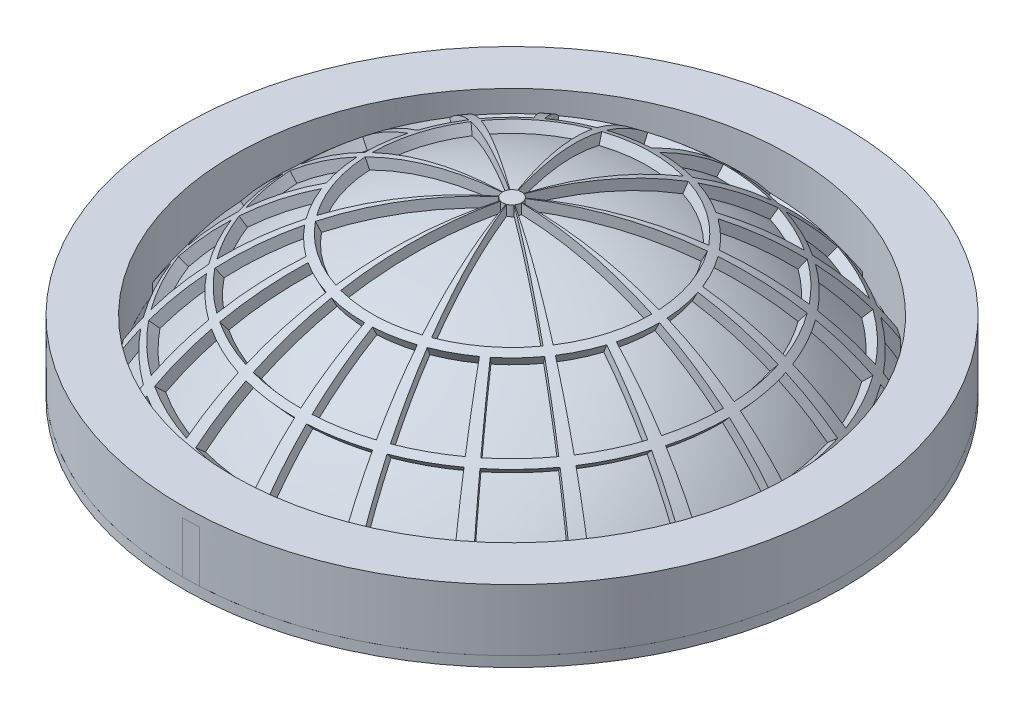
from build123d import *

# Parameters (mm, degrees)
REVOLVE_2_ANGLE          = 3
REVOLVE_3_ANGLE          = 3
PATTERN_CIRCULAR_3_COUNT = 20
PATTERN_CIRCULAR_4_COUNT = 10
EXTRUDE_START            = -60
SKETCH_2_R               = 321.293199325
SKETCH_2_R_2             = 271.293199325
EXTRUDE_1_DEPTH          = 10
SKETCH_2_2_R             = 321.293199325
SKETCH_2_2_R_2           = 271.293199325
EXTRUDE_2_DEPTH          = 10
EXTRUDE_3_DEPTH          = 60
EXTRUDE_4_DEPTH          = 50


with BuildPart() as part:
    # Sketch 1 → Revolve 1 (revolve)
    with BuildSketch(Plane.XY):
        with BuildLine():
            Line((0, 310), (0, 300))
            ThreePointArc((0, 300), (150, 259.807621135), (259.807621135, 150))
            Line((259.807621135, 150), (271.293199325, 150))
            ThreePointArc((271.293199325, 150), (260.86202693, 167.484336301), (249.30566955, 184.246256761))
            ThreePointArc((249.30566955, 184.246256761), (246.702616609, 187.717391199), (244.051238042, 191.151754399))
            ThreePointArc((244.051238042, 191.151754399), (225.561573766, 212.654594214), (205.184234191, 232.377774409))
            ThreePointArc((205.184234191, 232.377774409), (202.413399752, 234.795263157), (199.614084683, 237.179714976))
            ThreePointArc((199.614084683, 237.179714976), (170.612647572, 258.826823356), (139.286048295, 276.946559376))
            ThreePointArc((139.286048295, 276.946559376), (135.698993593, 278.721694774), (132.089320414, 280.450372495))
            ThreePointArc((132.089320414, 280.450372495), (72.146553697, 301.487768889), (9.174001596, 309.864224613))
            ThreePointArc((9.174001596, 309.864224613), (4.58750314, 309.966054295), (0, 310))
        make_face()
        with BuildLine():
            Line((136.350266234, 289.497158705), (132.089320414, 280.450372495))
            ThreePointArc((132.089320414, 280.450372495), (135.698993593, 278.721694774), (139.286048295, 276.946559376))
            Line((139.286048295, 276.946559376), (143.779146627, 285.880319356))
            ThreePointArc((143.779146627, 285.880319356), (140.076380483, 287.712717186), (136.350266234, 289.497158705))
        make_face()
        with BuildLine():
            Line((206.053248705, 244.830673524), (199.614084683, 237.179714976))
            ThreePointArc((199.614084683, 237.179714976), (202.413399752, 234.795263157), (205.184234191, 232.377774409))
            Line((205.184234191, 232.377774409), (211.803080455, 239.873831648))
            ThreePointArc((211.803080455, 239.873831648), (208.94286426, 242.369303904), (206.053248705, 244.830673524))
        make_face()
        with BuildLine():
            ThreePointArc((244.051238042, 191.151754399), (246.702616609, 187.717391199), (249.30566955, 184.246256761))
            Line((249.30566955, 184.246256761), (257.347787922, 190.189684398))
            ThreePointArc((257.347787922, 190.189684398), (254.660765532, 193.772790915), (251.923858624, 197.317940025))
            Line((251.923858624, 197.317940025), (244.051238042, 191.151754399))
        make_face()
        with BuildLine():
            Line((0, 320), (0, 310))
            ThreePointArc((0, 310), (4.58750314, 309.966054295), (9.174001596, 309.864224613))
            Line((9.174001596, 309.864224613), (9.174001596, 319.868469366))
            ThreePointArc((9.174001596, 319.868469366), (4.587472223, 319.967115652), (0, 320))
        make_face()
    revolve(axis=Axis((0, 300, 0), (0, -1, 0)))

    # Sketch 1_3 → Revolve 2 (revolve)
    with BuildSketch(Plane.XY):
        with BuildLine():
            Line((9.174001596, 319.868469366), (9.174001596, 309.864224613))
            ThreePointArc((9.174001596, 309.864224613), (72.146553697, 301.487768889), (132.089320414, 280.450372495))
            Line((132.089320414, 280.450372495), (136.350266234, 289.497158705))
            ThreePointArc((136.350266234, 289.497158705), (74.329888064, 311.24759877), (9.174001596, 319.868469366))
        make_face()
    revolve_2 = revolve(axis=Axis((0, 300, 0), (0, 1, 0)), revolution_arc=REVOLVE_2_ANGLE)

    # Sketch 1_5 → Revolve 3 (revolve)
    with BuildSketch(Plane.XY):
        with BuildLine():
            ThreePointArc((249.30566955, 184.246256761), (260.86202693, 167.484336301), (271.293199325, 150))
            Line((271.293199325, 150), (282.665880502, 150))
            ThreePointArc((282.665880502, 150), (270.753565451, 170.565256708), (257.347787922, 190.189684398))
            Line((257.347787922, 190.189684398), (249.30566955, 184.246256761))
        make_face()
        with BuildLine():
            Line((143.779146627, 285.880319356), (139.286048295, 276.946559376))
            ThreePointArc((139.286048295, 276.946559376), (170.612647572, 258.826823356), (199.614084683, 237.179714976))
            Line((199.614084683, 237.179714976), (206.053248705, 244.830673524))
            ThreePointArc((206.053248705, 244.830673524), (176.116281365, 267.176075722), (143.779146627, 285.880319356))
        make_face()
        with BuildLine():
            ThreePointArc((205.184234191, 232.377774409), (225.561573766, 212.654594214), (244.051238042, 191.151754399))
            Line((244.051238042, 191.151754399), (251.923858624, 197.317940025))
            ThreePointArc((251.923858624, 197.317940025), (232.837753565, 219.514419834), (211.803080455, 239.873831648))
            Line((211.803080455, 239.873831648), (205.184234191, 232.377774409))
        make_face()
    revolve_3 = revolve(axis=Axis((0, 300, 0), (0, 1, 0)), revolution_arc=REVOLVE_3_ANGLE)

    # Pattern Circular 3: Revolve 3 ×20 about axis
    pattern_circular_3_axis = Axis((0, 0, 0), (0, 1, 0))
    for i in range(1, PATTERN_CIRCULAR_3_COUNT):
        add(revolve_3.rotate(pattern_circular_3_axis, i * 360 / PATTERN_CIRCULAR_3_COUNT))

    # Pattern Circular 4: Revolve 2 ×10 about axis
    pattern_circular_4_axis = Axis((0, 0, 0), (0, 1, 0))
    for i in range(1, PATTERN_CIRCULAR_4_COUNT):
        add(revolve_2.rotate(pattern_circular_4_axis, i * 360 / PATTERN_CIRCULAR_4_COUNT))


with BuildPart() as body_2:
    # Sketch 2 → Extrude 1 (new body)
    with BuildSketch(Plane(origin=(0, 150, 0), x_dir=(-1, 0, 0), z_dir=(0, -1, 0)).offset(EXTRUDE_START)):
        Circle(SKETCH_2_R)
        Circle(SKETCH_2_R_2, mode=Mode.SUBTRACT)
    extrude(amount=-EXTRUDE_1_DEPTH)


    add(part.part)  # Extrude 3 merges part
    # Sketch 4 → Extrude 3 (add)
    with BuildSketch(Plane(origin=(0, 220, 0), x_dir=(1, 0, 0), z_dir=(0, 1, 0))):
        Polygon((0, -271.293199325), (16.133300517, -270.813065812), (16.133300517, -320.887887816), (0, -321.293199325), align=None)
    extrude(amount=-EXTRUDE_3_DEPTH)

    # Sketch 6 → Extrude 4 (add)
    with BuildSketch(Plane.XZ.offset(-210)):
        with BuildLine():
            Line((16.133300517, 320.887887816), (16.133300517, 270.813065812))
            ThreePointArc((16.133300517, 270.813065812), (-8.070221709, -271.173139381), (0, 271.293199325))
            Line((0, 271.293199325), (0, 321.293199325))
            ThreePointArc((0, 321.293199325), (-8.069195483, -321.191855465), (16.133300517, 320.887887816))
        make_face()
    extrude(amount=EXTRUDE_4_DEPTH)


with BuildPart() as body_3:
    # Sketch 2_2 → Extrude 2 (new body)
    with BuildSketch(Plane(origin=(0, 150, 0), x_dir=(-1, 0, 0), z_dir=(0, -1, 0))):
        Circle(SKETCH_2_2_R)
        Circle(SKETCH_2_2_R_2, mode=Mode.SUBTRACT)
    extrude(amount=-EXTRUDE_2_DEPTH)


solid = Compound([body_2.part, body_3.part])
